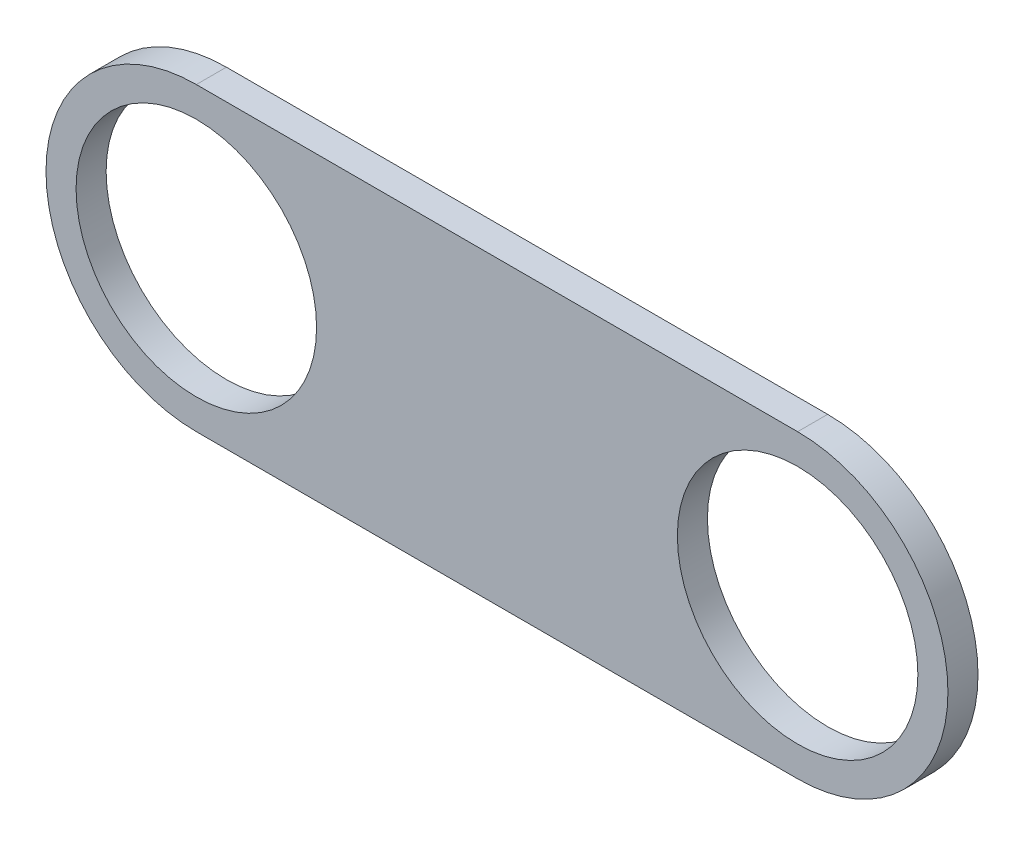
from build123d import *

# Parameters (mm, degrees)
SKETCH1_R           = 5.08
BOSS_EXTRUDE1_DEPTH = 1.27


with BuildPart() as part:
    # Sketch1 → Boss-Extrude1 (new body)
    with BuildSketch(Plane.XY):
        with BuildLine():
            Line((-83.611199938, -51.591945407), (-58.211199938, -51.591945407))
            ThreePointArc((-58.211199938, -51.591945407), (-51.861199938, -57.941945407), (-58.211199938, -64.291945407))
            Line((-58.211199938, -64.291945407), (-83.611199938, -64.291945407))
            ThreePointArc((-83.611199938, -64.291945407), (-89.961199938, -57.941945407), (-83.611199938, -51.591945407))
        make_face()
        with Locations((-58.211199938, -57.941945407)):
            Circle(SKETCH1_R, mode=Mode.SUBTRACT)
        with Locations((-83.611199938, -57.941945407)):
            Circle(SKETCH1_R, mode=Mode.SUBTRACT)
    extrude(amount=BOSS_EXTRUDE1_DEPTH)


solid = part.part
